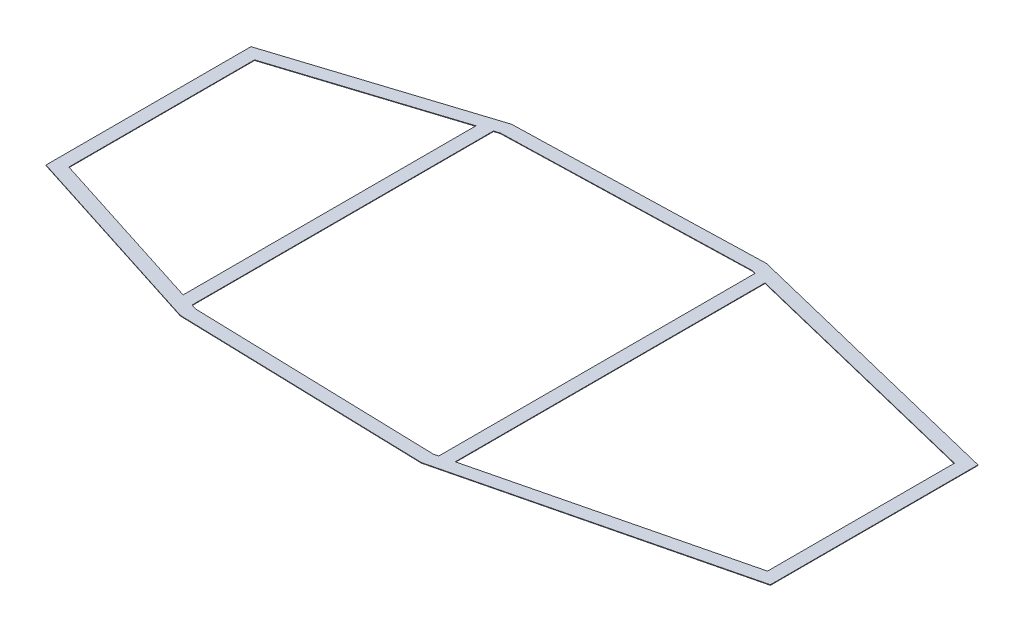
from build123d import *

# Parameters (mm, degrees)
BOSS_EXTRUDE1_DEPTH = 1


with BuildPart() as part:
    # Sketch1 → Boss-Extrude1 (new body)
    with BuildSketch(Plane(origin=(0, 60.3, 0), x_dir=(-1, 0, 0), z_dir=(0, 1, 0))):
        Polygon((-1549.465155864, 325.846398989), (-2078.8, 196.077711894), (-2078.8, -196.077711894), (-1549.465155864, -325.846398989), (-1080.847435472, -312.721773603), (-708, -193.60723205), (-708, 193.60723205), (-1080.847435472, 312.721773603), align=None)
        Polygon((-1580, 292.620355358), (-2053.8, 176.466271366), (-2053.8, -176.466271366), (-1580, -292.620355358), align=None, mode=Mode.SUBTRACT)
        Polygon((-1546.790935185, 300.76169876), (-1555, 298.749211626), (-1555, -298.749211626), (-1548.049652364, -300.796951783), (-1085.08461283, -287.83064162), (-1075, -284.608884087), (-1075, 284.608884087), (-1085.08461283, 287.83064162), align=None, mode=Mode.SUBTRACT)
        Polygon((-733, 175.349253107), (-733, -175.349253107), (-1050, -276.622068957), (-1050, 276.622068957), align=None, mode=Mode.SUBTRACT)
    extrude(amount=BOSS_EXTRUDE1_DEPTH)


solid = part.part
